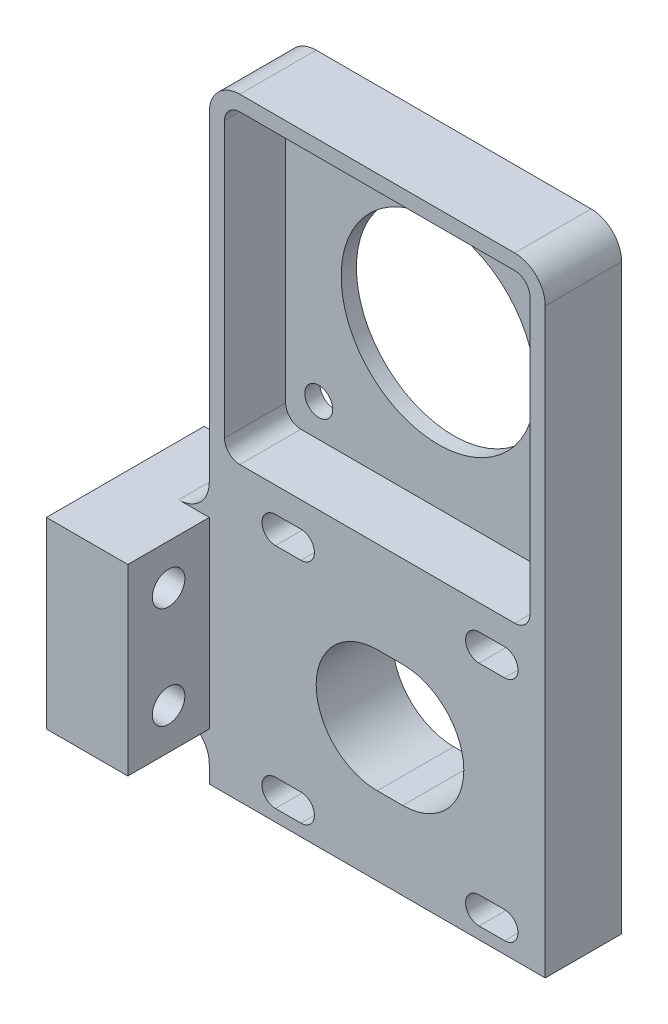
from build123d import *

# Parameters (mm, degrees)
STEPPER_PLATE_SKETCH_R                 = 19.1
PLATE_BOSS_EXTRUDE_DEPTH               = 15
CLEARANCE_HOLE1_D                      = 5.5
SHAFT_CLEARANCE_CUT_EXTRUDE_DEPTH      = 1
SHAFT_CLEARANCE_CUT_EXTRUDE_DEPTH_BACK = 16
STEPPER_PLATE_SKETCH_10_W              = 16
STEPPER_PLATE_SKETCH_10_H              = 36
BOSS_EXTRUDE1_DEPTH                    = 16
SKETCH18_W                             = 2.65
SKETCH18_H                             = 15
M5_CLEARANCE_HOLE1_AT_2_COUNT          = 2
M5_CLEARANCE_HOLE1_AT_2_PITCH          = 20
FILLET8_R                              = 6
STEPPER_PLATE_SKETCH_6_W               = 60
STEPPER_PLATE_SKETCH_6_H               = 60
STEPPER_PLATE_SKETCH_6_R               = 19.1
CUT_EXTRUDE1_DEPTH                     = 12
FILLET6_R                              = 3
FILLET7_R                              = 6
M5_CLEARANCE_HOLE3_D                   = 5.3
F_1_0MM_DOWEL_HOLE1_D                  = 6.4
F_1_0MM_DOWEL_HOLE1_DEPTH              = 10
F_1_0MM_DOWEL_HOLE1_TIP                = 1.922753981


with BuildPart() as part:
    # Stepper Plate Sketch → Plate Boss-Extrude (new body)
    with BuildSketch(Plane.XY):
        Polygon((33, 93), (-33, 93), (-33, 18), (-49, 18), (-49, -18), (-33, -18), (-33, -27.360679775), (33, -27.360679775), align=None)
        with BuildLine():
            ThreePointArc((-20, -25.010679775), (-22.65, -22.360679775), (-20, -19.710679775))
            Line((-20, -19.710679775), (-15, -19.710679775))
            ThreePointArc((-15, -19.710679775), (-12.35, -22.360679775), (-15, -25.010679775))
            Line((-15, -25.010679775), (-20, -25.010679775))
        make_face(mode=Mode.SUBTRACT)
        with BuildLine():
            ThreePointArc((-20, 19.710679775), (-22.65, 22.360679775), (-20, 25.010679775))
            Line((-20, 25.010679775), (-15, 25.010679775))
            ThreePointArc((-15, 25.010679775), (-12.35, 22.360679775), (-15, 19.710679775))
            Line((-15, 19.710679775), (-20, 19.710679775))
        make_face(mode=Mode.SUBTRACT)
        with BuildLine():
            ThreePointArc((20, -25.010679775), (17.35, -22.360679775), (20, -19.710679775))
            Line((20, -19.710679775), (25, -19.710679775))
            ThreePointArc((25, -19.710679775), (27.65, -22.360679775), (25, -25.010679775))
            Line((25, -25.010679775), (20, -25.010679775))
        make_face(mode=Mode.SUBTRACT)
        with BuildLine():
            ThreePointArc((20, 19.710679775), (17.35, 22.360679775), (20, 25.010679775))
            Line((20, 25.010679775), (25, 25.010679775))
            ThreePointArc((25, 25.010679775), (27.65, 22.360679775), (25, 19.710679775))
            Line((25, 19.710679775), (20, 19.710679775))
        make_face(mode=Mode.SUBTRACT)
        with Locations((0, 60)):
            Circle(STEPPER_PLATE_SKETCH_R, mode=Mode.SUBTRACT)
    extrude(amount=-PLATE_BOSS_EXTRUDE_DEPTH)

    # Clearance Hole1 (through all)
    with Locations(Plane.XY):
        with Locations((-23.5, 83.5), (-23.5, 36.5), (23.5, 36.5), (23.5, 83.5)):
            Hole(CLEARANCE_HOLE1_D / 2)

    # Stepper Plate Sketch_5 → Shaft Clearance Cut-Extrude (cut, two sides)
    with BuildSketch(Plane.XY) as shaft_clearance_cut_extrude_sk:
        with BuildLine():
            Line((0, 12), (5, 12))
            ThreePointArc((5, 12), (17, 0), (5, -12))
            Line((5, -12), (0, -12))
            ThreePointArc((0, -12), (-12, 0), (0, 12))
        make_face()
    extrude(amount=SHAFT_CLEARANCE_CUT_EXTRUDE_DEPTH, mode=Mode.SUBTRACT)
    extrude(shaft_clearance_cut_extrude_sk.sketch, amount=-SHAFT_CLEARANCE_CUT_EXTRUDE_DEPTH_BACK, mode=Mode.SUBTRACT)

    # Stepper Plate Sketch_10 → Boss-Extrude1 (add)
    with BuildSketch(Plane.XY):
        with Locations((-41, 0)):
            Rectangle(STEPPER_PLATE_SKETCH_10_W, STEPPER_PLATE_SKETCH_10_H)
    extrude(amount=BOSS_EXTRUDE1_DEPTH)

    # Sketch18 → M5 Clearance Hole1 (revolve, cut)
    with BuildSketch(Plane(origin=(-41, 10, 0), x_dir=(0, -1, 0), z_dir=(1, 0, 0))):
        with Locations((1.325, 7.5)):
            Rectangle(SKETCH18_W, SKETCH18_H)
    m5_clearance_hole1 = revolve(axis=Axis((-41, 10, 6.35), (0, 0, -1)), mode=Mode.SUBTRACT)

    # M5 Clearance Hole1 at 2: M5 Clearance Hole1 ×2
    with Locations(*[(0, -i * M5_CLEARANCE_HOLE1_AT_2_PITCH, 0) for i in range(1, M5_CLEARANCE_HOLE1_AT_2_COUNT)]):
        add(m5_clearance_hole1, mode=Mode.SUBTRACT)

    # Fillet8
    fillet8_edges = [part.edges().sort_by_distance(p)[0] for p in [
        (-33, -18, -7.5),
        (-33, 18, -7.5),
    ]]
    fillet(fillet8_edges, radius=FILLET8_R)

    # Stepper Plate Sketch_6 → Cut-Extrude1 (cut)
    with BuildSketch(Plane.XY):
        with Locations((0, 60)):
            Rectangle(STEPPER_PLATE_SKETCH_6_W, STEPPER_PLATE_SKETCH_6_H)
        with Locations((0, 60)):
            Circle(STEPPER_PLATE_SKETCH_6_R, mode=Mode.SUBTRACT)
    extrude(amount=-CUT_EXTRUDE1_DEPTH, mode=Mode.SUBTRACT)

    # Fillet6
    fillet6_edges = [part.edges().sort_by_distance(p)[0] for p in [
        (30, 90, -6),
        (30, 30, -6),
        (-30, 30, -6),
        (-30, 90, -6),
    ]]
    fillet(fillet6_edges, radius=FILLET6_R)

    # Fillet7
    fillet7_edges = [part.edges().sort_by_distance(p)[0] for p in [
        (-33, 93, -7.5),
        (33, 93, -7.5),
    ]]
    fillet(fillet7_edges, radius=FILLET7_R)

    # M5 Clearance Hole3 (through all)
    with Locations(Plane.ZY.offset(49)):
        with Locations((8, 10), (8, -10)):
            Hole(M5_CLEARANCE_HOLE3_D / 2)

    # 1.0mm Dowel Hole1
    with Locations(Plane(origin=(-33, 0, 0), x_dir=(0, 0, -1), z_dir=(1, 0, 0))):
        with Locations((-8, 10), (-8, -10)):
            Hole(F_1_0MM_DOWEL_HOLE1_D / 2, depth=F_1_0MM_DOWEL_HOLE1_DEPTH)
            with Locations((0, 0, -(F_1_0MM_DOWEL_HOLE1_DEPTH + F_1_0MM_DOWEL_HOLE1_TIP / 2))):  # 118° drill point
                Cone(0, F_1_0MM_DOWEL_HOLE1_D / 2, F_1_0MM_DOWEL_HOLE1_TIP, mode=Mode.SUBTRACT)


solid = part.part
